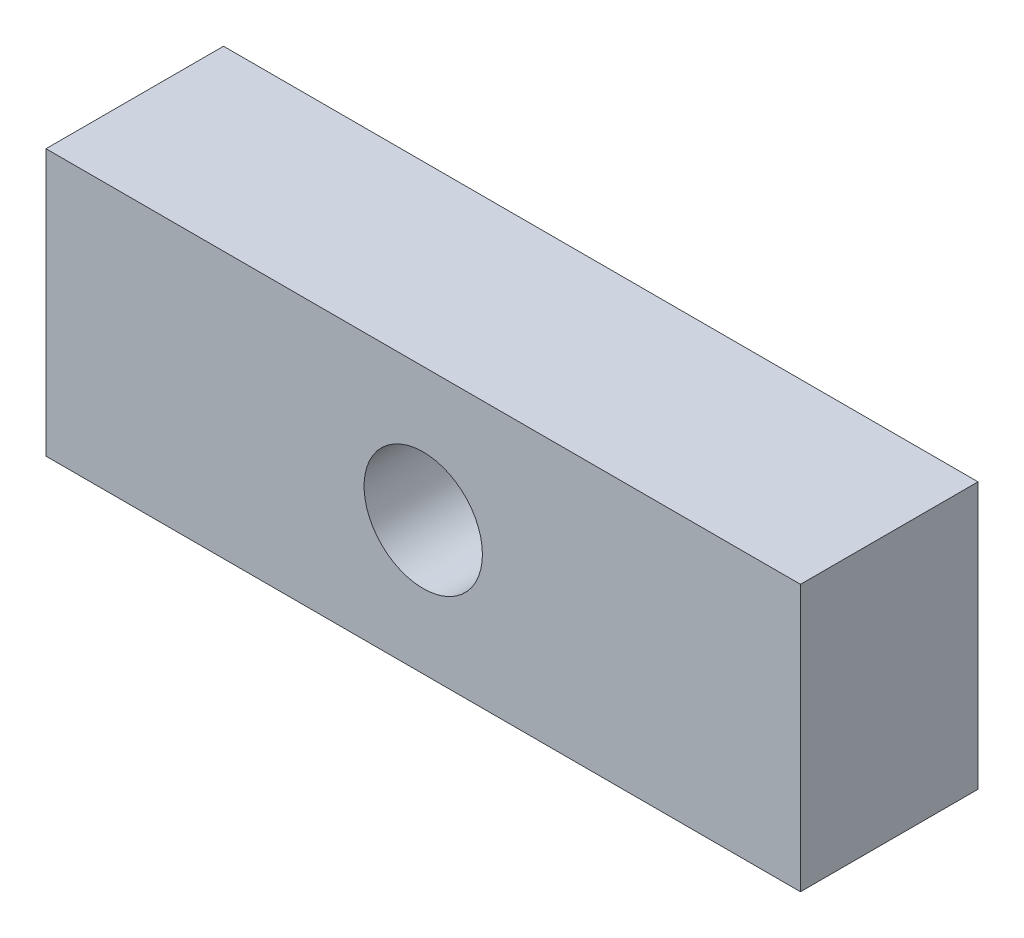
from build123d import *

# Parameters (mm, degrees)
SKETCH1_W           = 12.75
SKETCH1_H           = 4.5
BOSS_EXTRUDE1_DEPTH = 3
SKETCH2_R           = 1
CUT_EXTRUDE1_DEPTH  = 3


with BuildPart() as part:
    # Sketch1 → Boss-Extrude1 (new body)
    with BuildSketch(Plane.XY):
        with Locations((6.375, -2.25)):
            Rectangle(SKETCH1_W, SKETCH1_H)
    extrude(amount=BOSS_EXTRUDE1_DEPTH)

    # Sketch2 → Cut-Extrude1 (cut)
    with BuildSketch(Plane.XY.offset(3)):
        with Locations((6.375, -2.25)):
            Circle(SKETCH2_R)
    extrude(amount=-CUT_EXTRUDE1_DEPTH, mode=Mode.SUBTRACT)


solid = part.part
